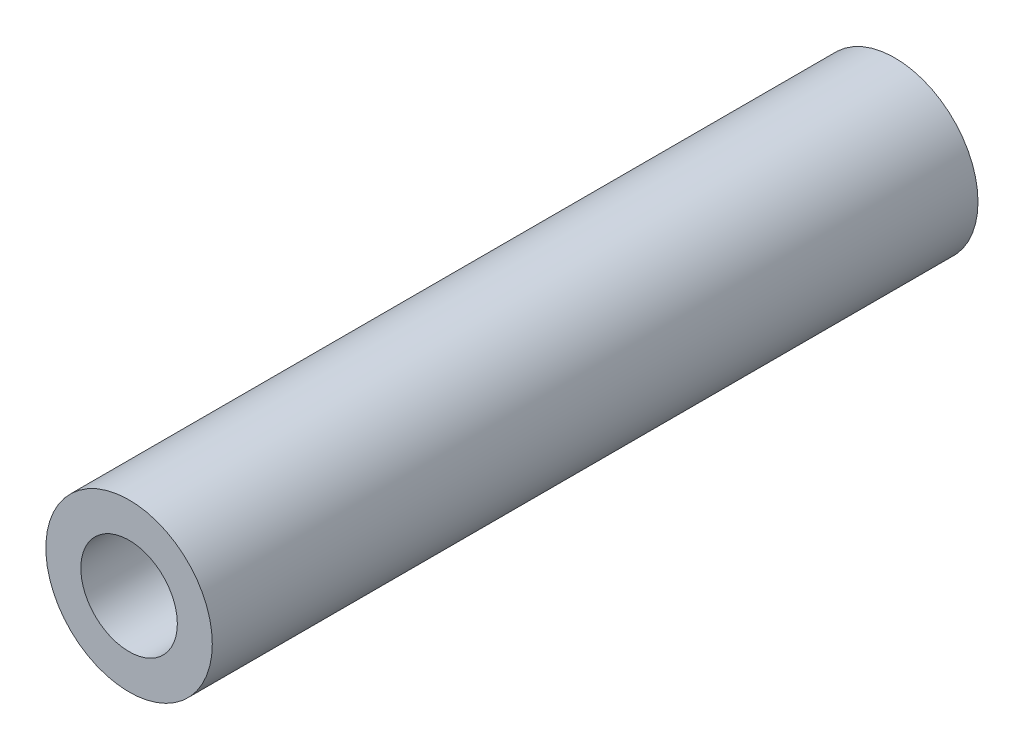
from build123d import *

# Parameters (mm, degrees)
SKETCH_1_R      = 2.5
SKETCH_1_R_2    = 1.45
EXTRUDE_1_DEPTH = 23


with BuildPart() as part:
    # 草图1 → 凸台-拉伸1 (new body)
    with BuildSketch(Plane.XY):
        Circle(SKETCH_1_R)
        Circle(SKETCH_1_R_2, mode=Mode.SUBTRACT)
    extrude(amount=EXTRUDE_1_DEPTH)


solid = part.part
